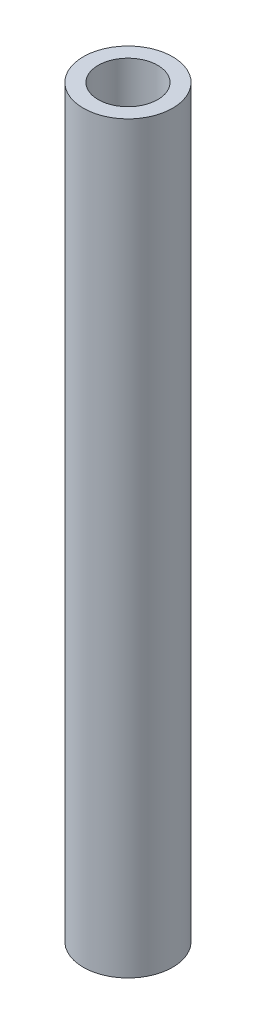
from build123d import *

# Parameters (mm, degrees)
SKETCH1_R           = 3
SKETCH1_R_2         = 2
BOSS_EXTRUDE1_DEPTH = 50


with BuildPart() as part:
    # Sketch1 → Boss-Extrude1 (new body)
    with BuildSketch(Plane(origin=(0, 0, 0), x_dir=(1, 0, 0), z_dir=(0, 1, 0))):
        Circle(SKETCH1_R)
        Circle(SKETCH1_R_2, mode=Mode.SUBTRACT)
    extrude(amount=BOSS_EXTRUDE1_DEPTH)


solid = part.part
